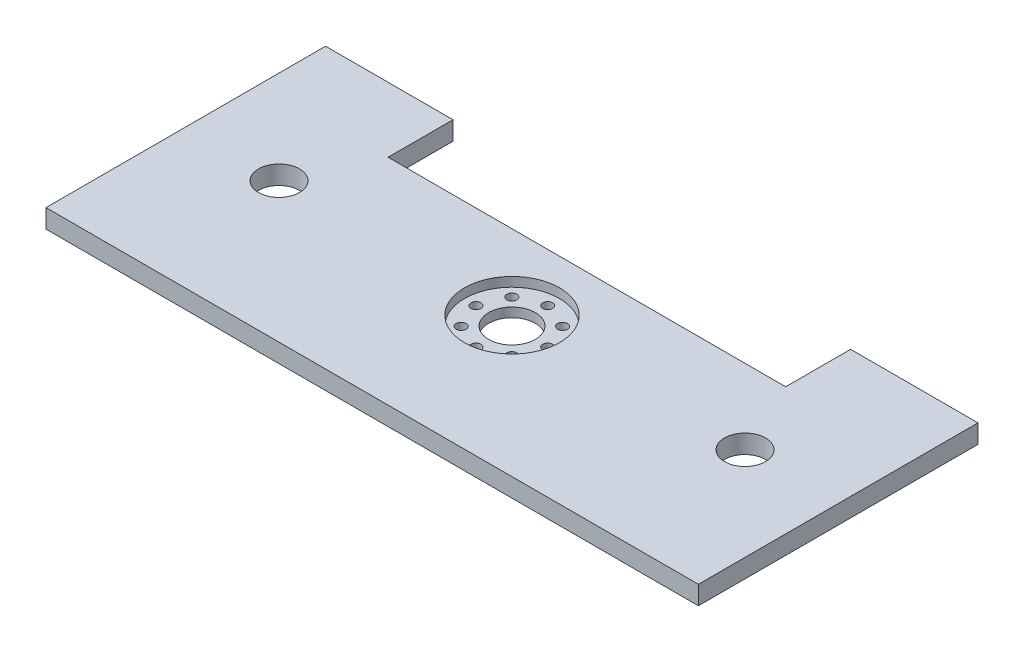
from build123d import *

# Parameters (mm, degrees)
SKETCH1_W             = 177.8
SKETCH1_H             = 76.2
SKETCH1_R             = 5.588
BOSS_EXTRUDE1_DEPTH   = 5.08
SKETCH2_R             = 12.954
SKETCH2_R_2           = 0.712100007
CUT_EXTRUDE1_DEPTH    = 2.54
SKETCH4_R             = 6.35
CUT_EXTRUDE2_DEPTH    = 6.08
F_6_32_TAPPED_HOLE2_D = 2.7051
SKETCH9_W             = 108.359679772
SKETCH9_H             = 17.691365346
CUT_EXTRUDE7_DEPTH    = 5.08


with BuildPart() as part:
    # Sketch1 → Boss-Extrude1 (new body)
    with BuildSketch(Plane(origin=(0, 0, 0), x_dir=(1, 0, 0), z_dir=(0, 1, 0))):
        Rectangle(SKETCH1_W, SKETCH1_H)
        with Locations((-63.5, 0)):
            Circle(SKETCH1_R, mode=Mode.SUBTRACT)
        with Locations((63.5, 0)):
            Circle(SKETCH1_R, mode=Mode.SUBTRACT)
    extrude(amount=BOSS_EXTRUDE1_DEPTH)

    # Sketch2 → Cut-Extrude1 (cut)
    with BuildSketch(Plane(origin=(0, 5.08, 0), x_dir=(1, 0, 0), z_dir=(0, 1, 0))):
        Circle(SKETCH2_R)
        with Locations((6.980537549, -7.023044726)):
            Circle(SKETCH2_R_2, mode=Mode.SUBTRACT)
        with Locations((9.844740335, -0.108247513)):
            Circle(SKETCH2_R_2, mode=Mode.SUBTRACT)
        with Locations((-6.849056878, -7.023044726)):
            Circle(SKETCH2_R_2, mode=Mode.SUBTRACT)
        with Locations((0.065740335, -9.887247513)):
            Circle(SKETCH2_R_2, mode=Mode.SUBTRACT)
        with Locations((6.980537549, 6.8065497)):
            Circle(SKETCH2_R_2, mode=Mode.SUBTRACT)
        with Locations((0.065740335, 9.670752487)):
            Circle(SKETCH2_R_2, mode=Mode.SUBTRACT)
        with Locations((-6.849056878, 6.8065497)):
            Circle(SKETCH2_R_2, mode=Mode.SUBTRACT)
        with Locations((-9.713259665, -0.108247513)):
            Circle(SKETCH2_R_2, mode=Mode.SUBTRACT)
    extrude(amount=-CUT_EXTRUDE1_DEPTH, mode=Mode.SUBTRACT)

    # Sketch4 → Cut-Extrude2 (cut, through all)
    with BuildSketch(Plane(origin=(0, 5.08, 0), x_dir=(1, 0, 0), z_dir=(0, 1, 0))):
        Circle(SKETCH4_R)
    extrude(amount=-CUT_EXTRUDE2_DEPTH, mode=Mode.SUBTRACT)

    # #6-32 Tapped Hole2 (through all)
    with Locations(Plane(origin=(0, 2.54, 0), x_dir=(1, 0, 0), z_dir=(0, 1, 0))):
        with Locations((6.980537549, 6.8065497), (9.844740335, -0.108247513), (6.980537549, -7.023044726), (0.065740335, 9.670752487), (-6.849056878, 6.8065497), (-9.713259665, -0.108247513), (-6.849056878, -7.023044726), (0.065740335, -9.887247513)):
            Hole(F_6_32_TAPPED_HOLE2_D / 2)

    # Sketch9 → Cut-Extrude7 (cut)
    with BuildSketch(Plane(origin=(0, 0, 0), x_dir=(1, 0, 0), z_dir=(0, 1, 0))):
        with Locations((0, 29.254317327)):
            Rectangle(SKETCH9_W, SKETCH9_H)
    extrude(amount=CUT_EXTRUDE7_DEPTH, mode=Mode.SUBTRACT)


solid = part.part
